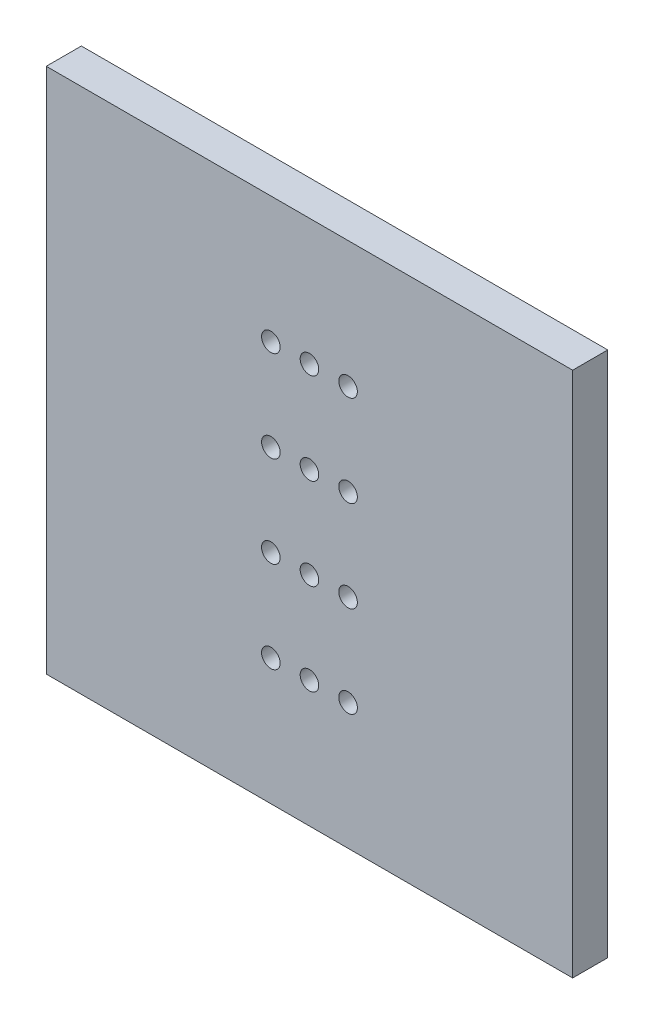
from build123d import *

# Parameters (mm, degrees)
ESQUISSE1_W            = 30
ESQUISSE1_H            = 30
BASE_PLATE_DEPTH       = 2
SKETCH_PERFORATIONS_R  = 0.53
CUT_PERFORATIONS_DEPTH = 10


with BuildPart() as part:
    # Esquisse1 → Base_Plate (new body)
    with BuildSketch(Plane.XY):
        Rectangle(ESQUISSE1_W, ESQUISSE1_H)
    extrude(amount=BASE_PLATE_DEPTH)

    # Sketch_Perforations → Cut_Perforations (cut)
    with BuildSketch(Plane.XY.offset(2)):
        with Locations((-2.2, -7.8)):
            Circle(SKETCH_PERFORATIONS_R)
        with Locations((-2.2, -2.6)):
            Circle(SKETCH_PERFORATIONS_R)
        with Locations((-2.2, 2.6)):
            Circle(SKETCH_PERFORATIONS_R)
        with Locations((-2.2, 7.8)):
            Circle(SKETCH_PERFORATIONS_R)
        with Locations((0, -7.8)):
            Circle(SKETCH_PERFORATIONS_R)
        with Locations((0, -2.6)):
            Circle(SKETCH_PERFORATIONS_R)
        with Locations((0, 2.6)):
            Circle(SKETCH_PERFORATIONS_R)
        with Locations((0, 7.8)):
            Circle(SKETCH_PERFORATIONS_R)
        with Locations((2.2, -7.8)):
            Circle(SKETCH_PERFORATIONS_R)
        with Locations((2.2, -2.6)):
            Circle(SKETCH_PERFORATIONS_R)
        with Locations((2.2, 2.6)):
            Circle(SKETCH_PERFORATIONS_R)
        with Locations((2.2, 7.8)):
            Circle(SKETCH_PERFORATIONS_R)
    extrude(amount=-CUT_PERFORATIONS_DEPTH, mode=Mode.SUBTRACT)


solid = part.part
